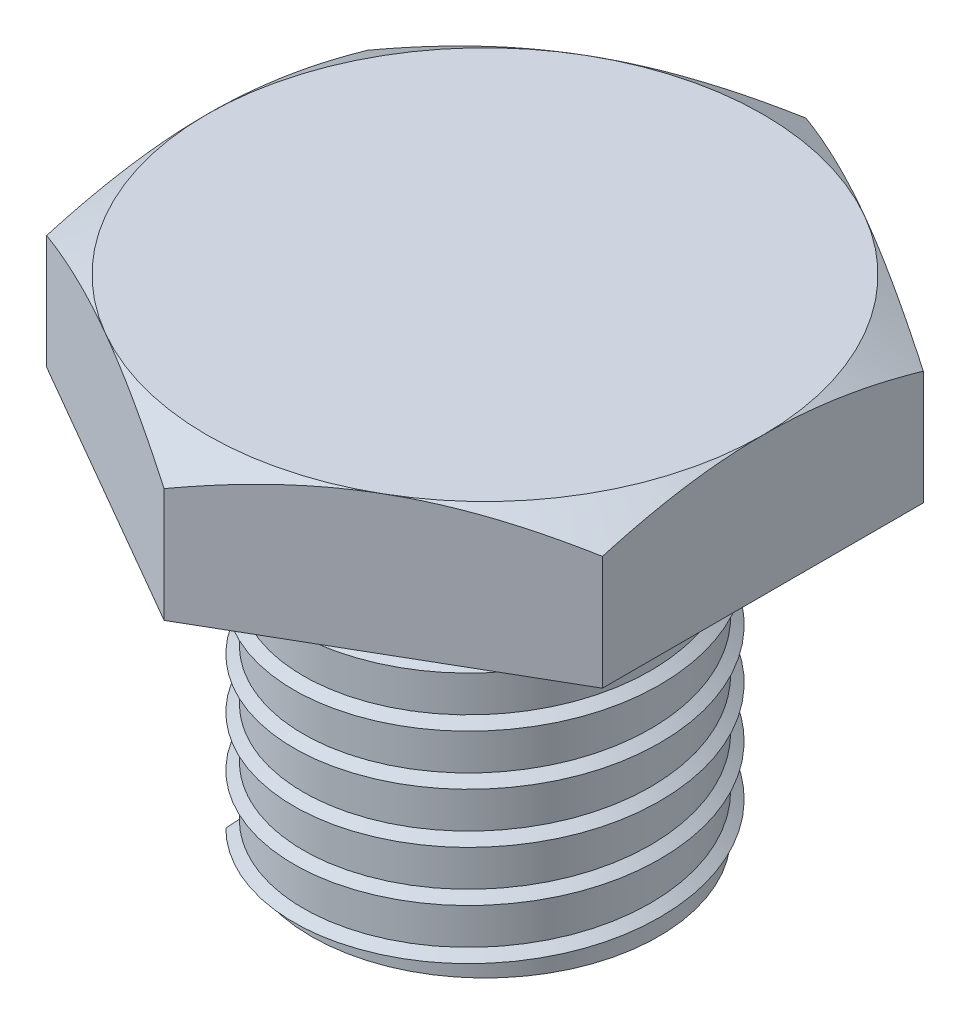
from build123d import *

# Parameters (mm, degrees)
SALIENTE_EXTRUIR1_DEPTH = 5.08
CROQUIS2_OUTSIDE_W      = 33.01
CROQUIS2_OUTSIDE_H      = 36.154
CROQUIS2_OUTSIDE_R      = 10.16
CORTAR_EXTRUIR1_DEPTH   = 1.27
CORTAR_EXTRUIR1_TAPER   = 60
CROQUIS3_R              = 6.35
SALIENTE_EXTRUIR2_DEPTH = 12.7
BARRER3_PITCH           = 1.84
BARRER3_HEIGHT          = 10.12
BARRER3_RADIUS          = 6.35
BARRER3_START_ANGLE     = -45


with BuildPart() as part:
    # Croquis1 → Saliente-Extruir1 (new body)
    with BuildSketch(Plane(origin=(0, 0, 0), x_dir=(1, 0, 0), z_dir=(0, 1, 0))):
        Polygon((0, 11.73175747), (-10.16, 5.865878735), (-10.16, -5.865878735), (0, -11.73175747), (10.16, -5.865878735), (10.16, 5.865878735), align=None)
    extrude(amount=SALIENTE_EXTRUIR1_DEPTH)

    # Croquis2 outside → Cortar-Extruir1 (cut)
    with BuildSketch(Plane(origin=(0, 5.08, 0), x_dir=(1, 0, 0), z_dir=(0, 1, 0))):
        Rectangle(CROQUIS2_OUTSIDE_W, CROQUIS2_OUTSIDE_H)
        Circle(CROQUIS2_OUTSIDE_R, mode=Mode.SUBTRACT)
    extrude(amount=-CORTAR_EXTRUIR1_DEPTH, taper=CORTAR_EXTRUIR1_TAPER, mode=Mode.SUBTRACT)

    # Croquis3 → Saliente-Extruir2 (add)
    with BuildSketch(Plane.XZ):
        Circle(CROQUIS3_R)
    extrude(amount=SALIENTE_EXTRUIR2_DEPTH)


with BuildPart() as body_2:
    # Barrer3: sweep along a helix
    with BuildLine() as barrer3_path:
        add(Helix(BARRER3_PITCH, BARRER3_HEIGHT, BARRER3_RADIUS, center=(0, -12.7, 0), direction=(0, 1, 0), mode=Mode.PRIVATE).rotate(Axis((0, -12.7, 0), (0, 1, 0)), BARRER3_START_ANGLE))
    # Croquis5 → Barrer3 (sweep)
    with BuildSketch(Plane(origin=(4.490128061, -2.58, -4.490128061), x_dir=(-0.704858529, 0.045970707, 0.707856728), z_dir=(-0.706356038, 0.046068375, -0.706356038))):
        Polygon((0.000618506, 0.013425832), (0.024021241, 0.521425832), (-0.338054001, 0.267425832), align=None)
    sweep(path=barrer3_path.line, is_frenet=True)


solid = Compound([part.part, body_2.part])
